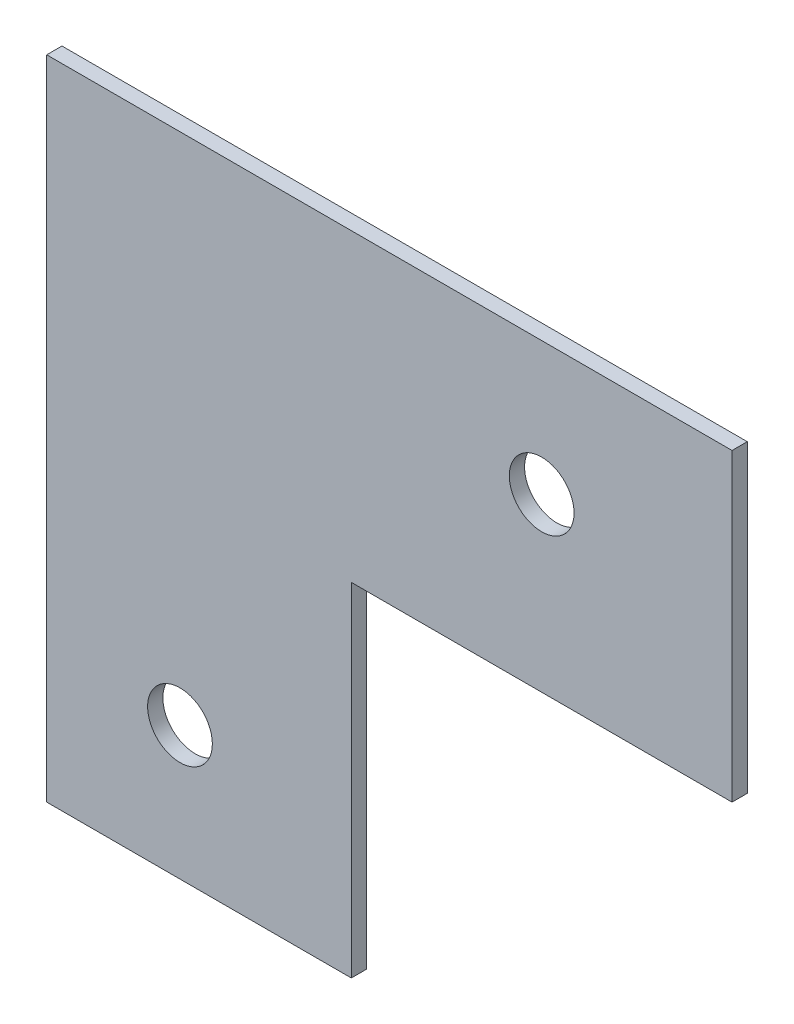
from build123d import *

# Parameters (mm, degrees)
BOSS_EXTRUDE1_DEPTH = 2
CUT_EXTRUDE1_REACH  = 4
SKETCH2_R           = 4.25


with BuildPart() as part:
    # Sketch1 → Boss-Extrude1 (new body)
    with BuildSketch(Plane.XY):
        Polygon((40, 0), (40, -45), (0, -45), (0, 0), (0, 40), (90, 40), (90, 0), align=None)
    extrude(amount=BOSS_EXTRUDE1_DEPTH)

    # Sketch2 → Cut-Extrude1 (cut, up to next)
    with BuildSketch(Plane.XY.offset(2), mode=Mode.PRIVATE) as cut_extrude1_sk1:
        with Locations((17.5, -27.5)):
            Circle(SKETCH2_R)
    cut_extrude1_tool1 = extrude(cut_extrude1_sk1.sketch, amount=-CUT_EXTRUDE1_REACH, mode=Mode.PRIVATE) & part.part
    add(cut_extrude1_tool1.solids().sort_by_distance((17.5, -27.5, 2))[0], mode=Mode.SUBTRACT)
    # Sketch2 → Cut-Extrude1 (cut, up to next)
    with BuildSketch(Plane.XY.offset(2), mode=Mode.PRIVATE) as cut_extrude1_sk2:
        with Locations((65, 22.5)):
            Circle(SKETCH2_R)
    cut_extrude1_tool2 = extrude(cut_extrude1_sk2.sketch, amount=-CUT_EXTRUDE1_REACH, mode=Mode.PRIVATE) & part.part
    add(cut_extrude1_tool2.solids().sort_by_distance((65, 22.5, 2))[0], mode=Mode.SUBTRACT)


solid = part.part
